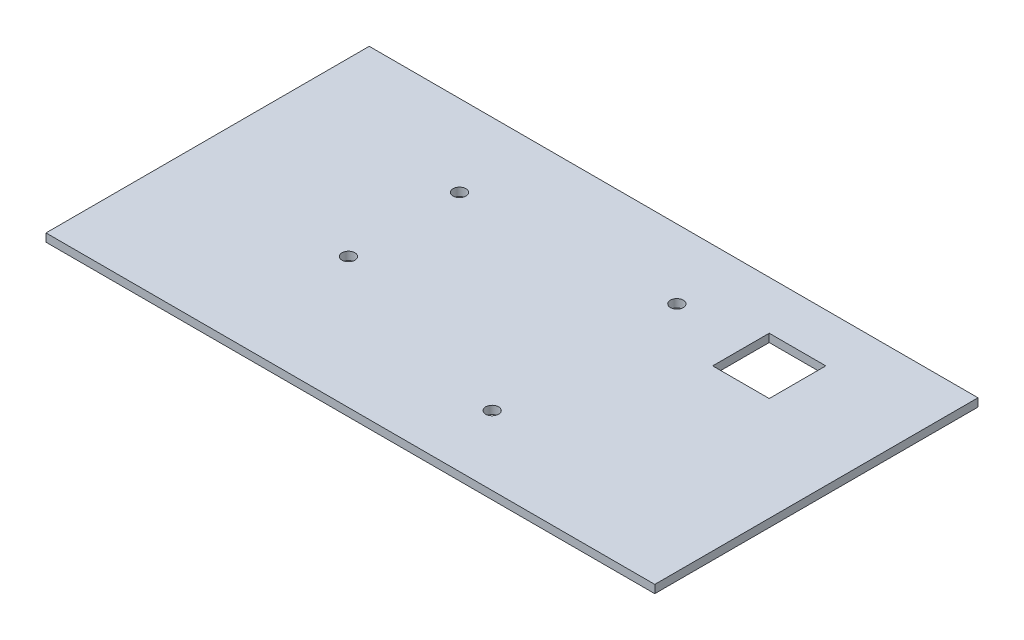
from build123d import *

# Parameters (mm, degrees)
SKETCH1_W           = 155
SKETCH1_H           = 110
BOSS_EXTRUDE1_DEPTH = 80
SKETCH2_W           = 151
SKETCH2_H           = 106
CUT_EXTRUDE1_DEPTH  = 78
SKETCH3_R           = 2.5
CUT_EXTRUDE2_DEPTH  = 2
SKETCH7_R           = 1.6
CUT_EXTRUDE7_DEPTH  = 2
SKETCH4_W           = 27.5
SKETCH4_H           = 46.8
CUT_EXTRUDE8_DEPTH  = 2
SKETCH8_W           = 4
SKETCH8_H           = 53
CUT_EXTRUDE9_DEPTH  = 2
SKETCH9_W           = 14
SKETCH9_H           = 14
CUT_EXTRUDE10_DEPTH = 2
SKETCH10_W          = 25.2
SKETCH10_H          = 71.2
SKETCH10_R          = 1.25
CUT_EXTRUDE12_DEPTH = 2
SKETCH11_R          = 2.5
SKETCH11_R_2        = 4.5
CUT_EXTRUDE13_DEPTH = 2
SKETCH12_W          = 150.672892958
SKETCH12_H          = 106
SKETCH12_W_2        = 2
SKETCH12_H_2        = 110
CUT_EXTRUDE14_DEPTH = 80
SKETCH13_W          = 150.672892958
SKETCH13_H          = 2
CUT_EXTRUDE15_DEPTH = 80
SKETCH14_W          = 2
SKETCH14_H          = 106
CUT_EXTRUDE16_DEPTH = 80


with BuildPart() as part:
    # Sketch1 → Boss-Extrude1 (new body)
    with BuildSketch(Plane.XY):
        with Locations((77.5, 55)):
            Rectangle(SKETCH1_W, SKETCH1_H)
    extrude(amount=BOSS_EXTRUDE1_DEPTH)

    # Sketch2 → Cut-Extrude1 (cut)
    with BuildSketch(Plane.XY.offset(80)):
        with Locations((77.5, 55)):
            Rectangle(SKETCH2_W, SKETCH2_H)
    extrude(amount=-CUT_EXTRUDE1_DEPTH, mode=Mode.SUBTRACT)

    # Sketch3 → Cut-Extrude2 (cut)
    with BuildSketch(Plane.XY.offset(2)):
        with Locations((145, 100.5)):
            Circle(SKETCH3_R)
        with Locations((145, 9.5)):
            Circle(SKETCH3_R)
        with Locations((10, 9.5)):
            Circle(SKETCH3_R)
        with Locations((10, 100.5)):
            Circle(SKETCH3_R)
    extrude(amount=-CUT_EXTRUDE2_DEPTH, mode=Mode.SUBTRACT)

    # Sketch7 → Cut-Extrude7 (cut)
    with BuildSketch(Plane(origin=(0, 110, 0), x_dir=(1, 0, 0), z_dir=(0, 1, 0))):
        with Locations((44.48, -20.14450396)):
            Circle(SKETCH7_R)
        with Locations((95.28, -17.14)):
            Circle(SKETCH7_R)
        with Locations((95.28, -62.86)):
            Circle(SKETCH7_R)
        with Locations((44.48, -47.62)):
            Circle(SKETCH7_R)
    extrude(amount=-CUT_EXTRUDE7_DEPTH, mode=Mode.SUBTRACT)

    # Sketch4 → Cut-Extrude8 (cut)
    with BuildSketch(Plane(origin=(155, 0, 0), x_dir=(0, 0, -1), z_dir=(1, 0, 0))):
        with Locations((-40, 82.5)):
            Rectangle(SKETCH4_W, SKETCH4_H)
    extrude(amount=-CUT_EXTRUDE8_DEPTH, mode=Mode.SUBTRACT)

    # Sketch8 → Cut-Extrude9 (cut)
    with BuildSketch(Plane(origin=(155, 0, 0), x_dir=(0, 0, -1), z_dir=(1, 0, 0))):
        with Locations((-68, 28.5)):
            Rectangle(SKETCH8_W, SKETCH8_H)
        with Locations((-76, 28.5)):
            Rectangle(SKETCH8_W, SKETCH8_H)
        with Locations((-60, 28.5)):
            Rectangle(SKETCH8_W, SKETCH8_H)
        with Locations((-52, 28.5)):
            Rectangle(SKETCH8_W, SKETCH8_H)
        with Locations((-44, 28.5)):
            Rectangle(SKETCH8_W, SKETCH8_H)
        with Locations((-36, 28.5)):
            Rectangle(SKETCH8_W, SKETCH8_H)
        with Locations((-28, 28.5)):
            Rectangle(SKETCH8_W, SKETCH8_H)
        with Locations((-20, 28.5)):
            Rectangle(SKETCH8_W, SKETCH8_H)
        with Locations((-12, 28.5)):
            Rectangle(SKETCH8_W, SKETCH8_H)
        with Locations((-4, 28.5)):
            Rectangle(SKETCH8_W, SKETCH8_H)
    extrude(amount=-CUT_EXTRUDE9_DEPTH, mode=Mode.SUBTRACT)

    # Sketch9 → Cut-Extrude10 (cut)
    with BuildSketch(Plane(origin=(0, 110, 0), x_dir=(1, 0, 0), z_dir=(0, 1, 0))):
        with Locations((120, -19)):
            Rectangle(SKETCH9_W, SKETCH9_H)
    extrude(amount=-CUT_EXTRUDE10_DEPTH, mode=Mode.SUBTRACT)

    # Sketch10 → Cut-Extrude12 (cut)
    with BuildSketch(Plane.ZY):
        with Locations((58, 55)):
            Rectangle(SKETCH10_W, SKETCH10_H)
        with Locations((42.5, 92.5)):
            Circle(SKETCH10_R)
        with Locations((73.5, 92.5)):
            Circle(SKETCH10_R)
        with Locations((42.5, 17.5)):
            Circle(SKETCH10_R)
        with Locations((73.5, 17.5)):
            Circle(SKETCH10_R)
    extrude(amount=-CUT_EXTRUDE12_DEPTH, mode=Mode.SUBTRACT)

    # Sketch11 → Cut-Extrude13 (cut)
    with BuildSketch(Plane.ZY):
        with Locations((20, 55)):
            Circle(SKETCH11_R)
        with Locations((20, 40)):
            Circle(SKETCH11_R)
        with Locations((20, 25)):
            Circle(SKETCH11_R)
        with Locations((20, 82.5)):
            Circle(SKETCH11_R_2)
    extrude(amount=-CUT_EXTRUDE13_DEPTH, mode=Mode.SUBTRACT)

    # Sketch12 → Cut-Extrude14 (cut)
    with BuildSketch(Plane.XY.offset(80)):
        with Locations((77.336446479, 55)):
            Rectangle(SKETCH12_W, SKETCH12_H)
        Polygon((155, 110), (152.672892958, 110), (152.672892958, 108), (153, 108), (153, 2), (152.672892958, 2), (152.672892958, 0), (155, 0), align=None)
        with Locations((1, 55)):
            Rectangle(SKETCH12_W_2, SKETCH12_H_2)
    extrude(amount=-CUT_EXTRUDE14_DEPTH, mode=Mode.SUBTRACT)

    # Sketch13 → Cut-Extrude15 (cut)
    with BuildSketch(Plane.XY.offset(80)):
        with Locations((77.336446479, 1)):
            Rectangle(SKETCH13_W, SKETCH13_H)
    extrude(amount=-CUT_EXTRUDE15_DEPTH, mode=Mode.SUBTRACT)

    # Sketch14 → Cut-Extrude16 (cut)
    with BuildSketch(Plane(origin=(153, 0, 0), x_dir=(0, 0, -1), z_dir=(1, 0, 0))):
        with Locations((-1, 55)):
            Rectangle(SKETCH14_W, SKETCH14_H)
    extrude(amount=-CUT_EXTRUDE16_DEPTH, mode=Mode.SUBTRACT)


solid = part.part
